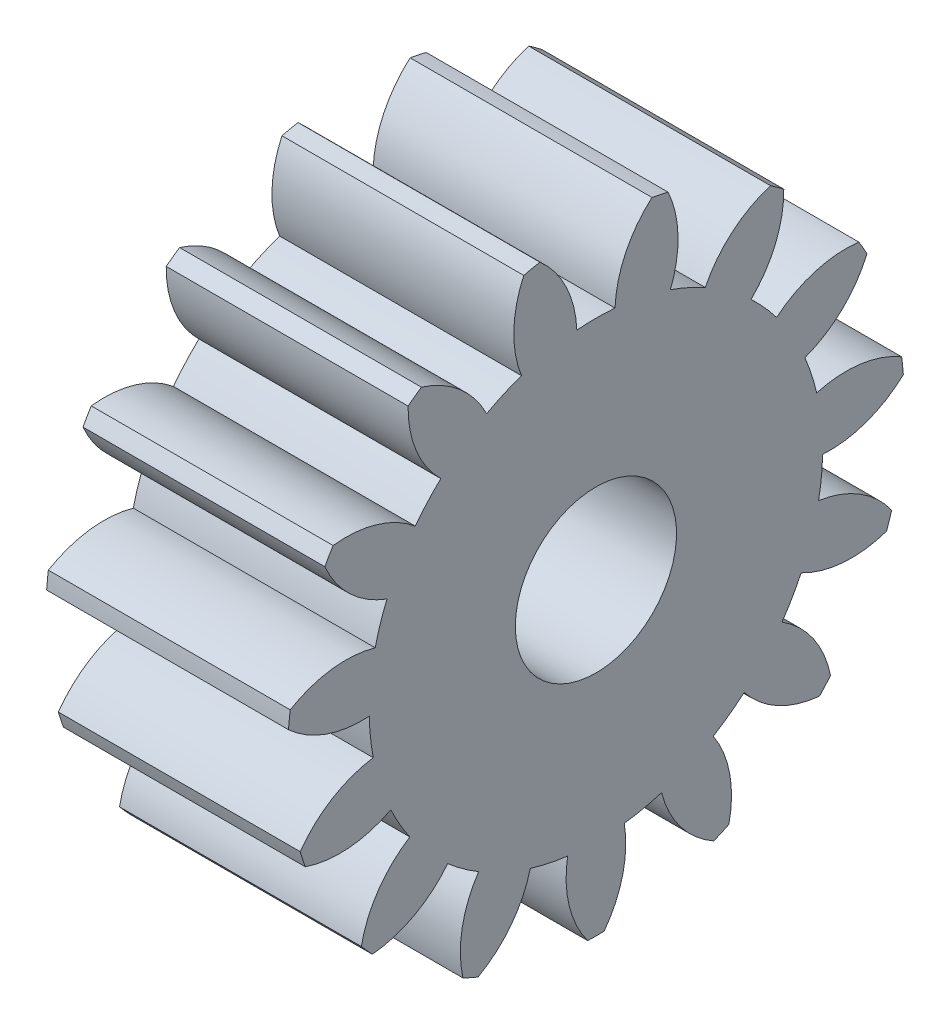
from build123d import *

# Parameters (mm, degrees)
BASPROSKE_W     = 15
BASPROSKE_H     = 19.125
TOOTHCUT_DEPTH  = 31.927839401
TEETHCUTS_COUNT = 15
TEETHCUTS_ANGLE = 336
BORSKE_R        = 5
BORE_DEPTH      = 50.0000508


with BuildPart() as part:
    # BasProSke → Base-Revolve (revolve)
    with BuildSketch(Plane(origin=(0, 0, 0), x_dir=(1, 0, 0), z_dir=(0, 1, 0)), mode=Mode.PRIVATE) as base_revolve_sk:
        with Locations((7.5, 9.5625)):
            Rectangle(BASPROSKE_W, BASPROSKE_H)
    revolve(base_revolve_sk.sketch.rotate(Axis((-10, 0, 0), (1, 0, 0)), 180), axis=Axis((-10, 0, 0), (1, 0, 0)))

    # TooCutSke → ToothCut (cut, through all)
    with BuildSketch(Plane(origin=(0, 0, 0), x_dir=(0, 0, -1), z_dir=(1, 0, 0))):
        with BuildLine():
            ThreePointArc((1.183690971, 14.011590129), (0, 14.0615), (-1.183690971, 14.011590129))
            ThreePointArc((-1.183690971, 14.011590129), (-1.84485156, 16.65872161), (-3.499927059, 18.827860493))
            ThreePointArc((-3.499927059, 18.827860493), (0, 19.1504), (3.499927059, 18.827860493))
            ThreePointArc((3.499927059, 18.827860493), (1.84485156, 16.65872161), (1.183690971, 14.011590129))
        make_face()
    toothcut = extrude(amount=TOOTHCUT_DEPTH, mode=Mode.SUBTRACT)

    # TeethCuts: ToothCut ×15 about axis
    teethcuts_axis = Axis((-10, 0, 0), (1, 0, 0))
    for i in range(1, TEETHCUTS_COUNT):
        add(toothcut.rotate(teethcuts_axis, i * TEETHCUTS_ANGLE / (TEETHCUTS_COUNT - 1)), mode=Mode.SUBTRACT)

    # BorSke → Bore (cut, symmetric)
    with BuildSketch(Plane(origin=(0, 0, 0), x_dir=(0, 0, -1), z_dir=(1, 0, 0))):
        with Locations(Location((0, 0, 0), (0, 0, 180))):
            Circle(BORSKE_R)
    extrude(amount=BORE_DEPTH, both=True, mode=Mode.SUBTRACT)


solid = part.part
